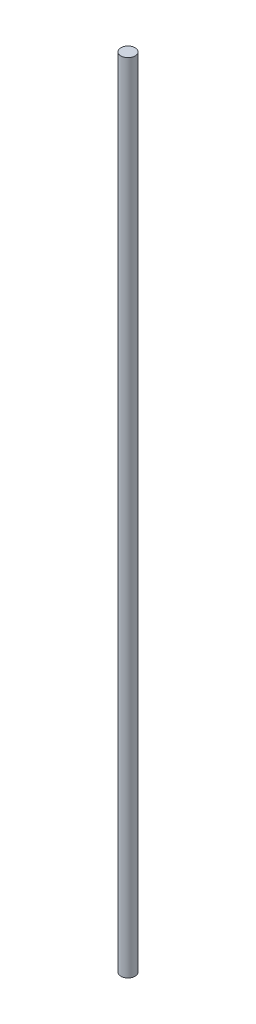
from build123d import *

# Parameters (mm, degrees)
SKETCH1_R           = 4
BOSS_EXTRUDE1_DEPTH = 446


with BuildPart() as part:
    # Sketch1 → Boss-Extrude1 (new body)
    with BuildSketch(Plane(origin=(0, 0, 0), x_dir=(1, 0, 0), z_dir=(0, 1, 0))):
        Circle(SKETCH1_R)
    extrude(amount=BOSS_EXTRUDE1_DEPTH)


solid = part.part
